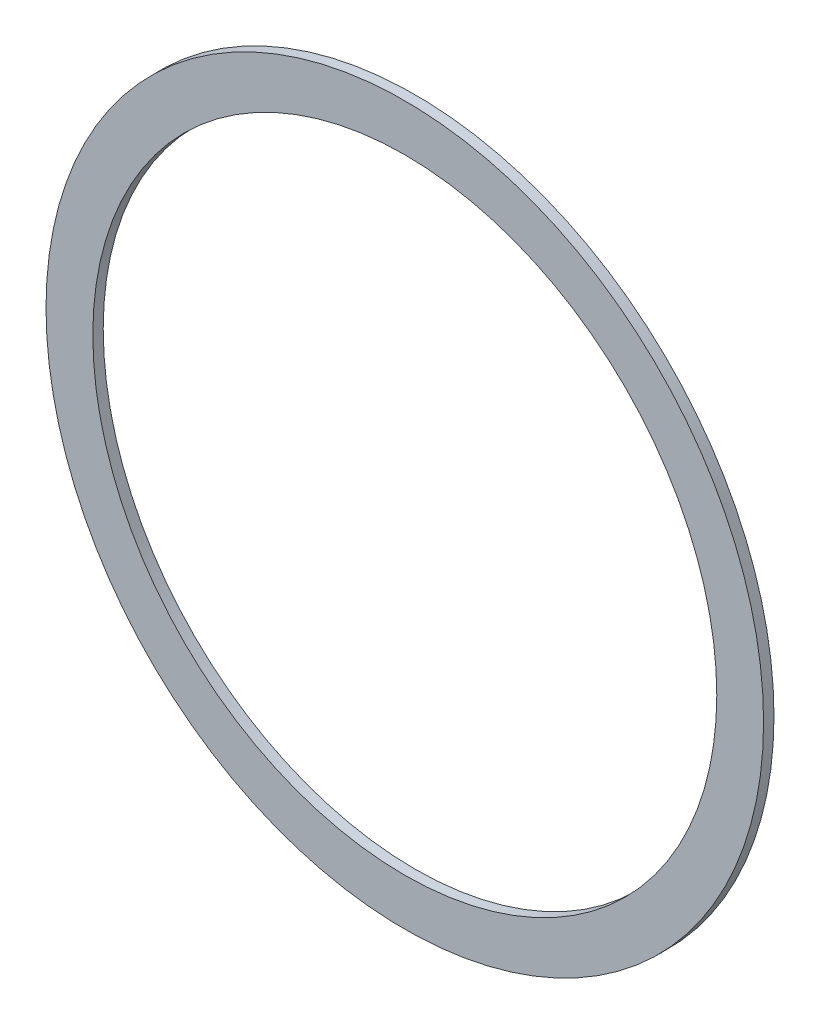
from build123d import *

# Parameters (mm, degrees)
SKETCH1_R           = 69
SKETCH1_R_2         = 60
BOSS_EXTRUDE1_DEPTH = 1


with BuildPart() as part:
    # Sketch1 → Boss-Extrude1 (new body, symmetric)
    with BuildSketch(Plane.XY):
        Circle(SKETCH1_R)
        Circle(SKETCH1_R_2, mode=Mode.SUBTRACT)
    extrude(amount=BOSS_EXTRUDE1_DEPTH, both=True)


solid = part.part
